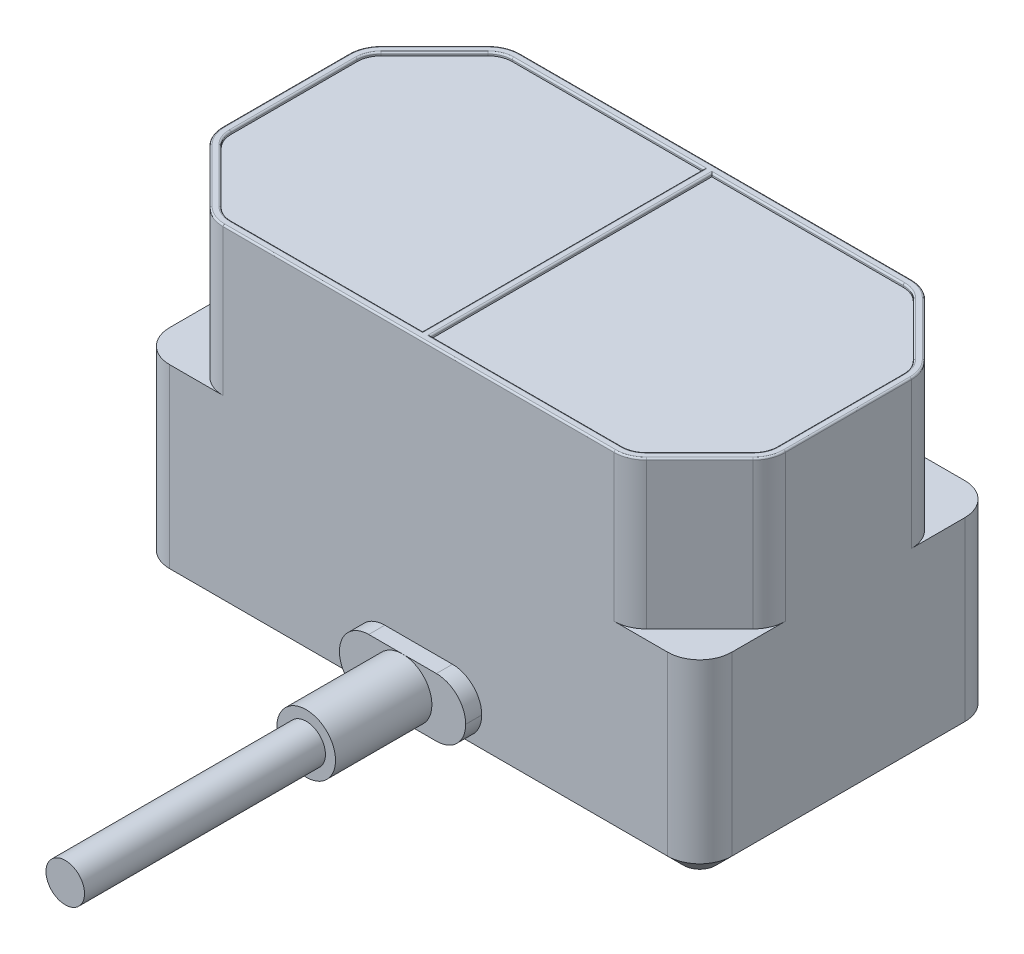
from build123d import *

# Parameters (mm, degrees)
SKETCH_1_W          = 35
SKETCH_1_H          = 18.5
EXTRUDE_1_DEPTH     = 12
EXTRUDE_2_DEPTH     = 9
FILLET_1_R          = 2
CHAMFER_1_SIZE      = 1
EXTRUDE_3_DEPTH     = 1
SKETCH_4_R          = 1.825
EXTRUDE_4_DEPTH     = 6
SKETCH_5_R          = 1.2
EXTRUDE_5_DEPTH     = 15
SKETCH_6_R          = 1
CUT_EXTRUDE_1_DEPTH = 4
FILLET_2_R          = 0.3
EXTRUDE_6_DEPTH     = 0.2
FILLET_3_R          = 0.1


with BuildPart() as part:
    # 草图1 → 凸台-拉伸1 (new body)
    with BuildSketch(Plane(origin=(0, 0, 0), x_dir=(1, 0, 0), z_dir=(0, 1, 0))):
        Rectangle(SKETCH_1_W, SKETCH_1_H)
    extrude(amount=EXTRUDE_1_DEPTH)

    # 草图2 → 凸台-拉伸2 (add)
    with BuildSketch(Plane(origin=(0, 12, 0), x_dir=(1, 0, 0), z_dir=(0, 1, 0))):
        Polygon((-13, 9.25), (-17.5, 4.75), (-17.5, -4.75), (-13, -9.25), (13, -9.25), (17.5, -4.75), (17.5, 4.75), (13, 9.25), align=None)
    extrude(amount=EXTRUDE_2_DEPTH)

    # 圆角1
    fillet_1_edges = [part.edges().sort_by_distance(p)[0] for p in [
        (13, 16.5, -9.25),
        (-13, 16.5, -9.25),
        (-17.5, 16.5, -4.75),
        (-17.5, 16.5, 4.75),
        (-13, 16.5, 9.25),
        (13, 16.5, 9.25),
        (17.5, 16.5, 4.75),
        (17.5, 16.5, -4.75),
        (17.5, 6, 9.25),
        (-17.5, 6, 9.25),
        (-17.5, 6, -9.25),
        (17.5, 6, -9.25),
    ]]
    fillet(fillet_1_edges, radius=FILLET_1_R)

    # 倒角1
    chamfer_1_edges = [part.edges().sort_by_distance(p)[0] for p in [
        (0, 0, -9.25),
        (-17.5, 0, 0),
        (17.5, 0, 0),
        (0, 0, 9.25),
        (-16.914213562, 0, 8.664213562),
        (-16.914213562, 0, -8.664213562),
        (16.914213562, 0, -8.664213562),
        (16.914213562, 0, 8.664213562),
    ]]
    chamfer(chamfer_1_edges, length=CHAMFER_1_SIZE)

    # 草图3 → 凸台-拉伸3 (add)
    with BuildSketch(Plane.XY.offset(9.25)):
        with BuildLine():
            Line((-2.106, 1), (2.106, 1))
            ThreePointArc((2.106, 1), (3.395762769, 1.534237231), (3.93, 2.824))
            Line((3.93, 2.824), (3.93, 2.826))
            ThreePointArc((3.93, 2.826), (3.395762769, 4.115762769), (2.106, 4.65))
            Line((2.106, 4.65), (-2.106, 4.65))
            ThreePointArc((-2.106, 4.65), (-3.395762769, 4.115762769), (-3.93, 2.826))
            Line((-3.93, 2.826), (-3.93, 2.824))
            ThreePointArc((-3.93, 2.824), (-3.395762769, 1.534237231), (-2.106, 1))
        make_face()
    extrude(amount=EXTRUDE_3_DEPTH)

    # 草图4 → 凸台-拉伸4 (add)
    with BuildSketch(Plane.XY.offset(10.25)):
        with Locations((0, 2.825)):
            Circle(SKETCH_4_R)
    extrude(amount=EXTRUDE_4_DEPTH)

    # 草图5 → 凸台-拉伸5 (add)
    with BuildSketch(Plane.XY.offset(16.25)):
        with Locations((0, 2.825)):
            Circle(SKETCH_5_R)
    extrude(amount=EXTRUDE_5_DEPTH)

    # 草图6 → 切除-拉伸1 (cut)
    with BuildSketch(Plane.XZ):
        with Locations((-14, 5.75)):
            Circle(SKETCH_6_R)
        with Locations((14, -5.75)):
            Circle(SKETCH_6_R)
    extrude(amount=-CUT_EXTRUDE_1_DEPTH, mode=Mode.SUBTRACT)

    # 圆角2
    fillet_2_edges = [part.edges().sort_by_distance(p)[0] for p in [
        (-15, 0, 5.75),
        (13, 0, -5.75),
    ]]
    fillet(fillet_2_edges, radius=FILLET_2_R)

    # 草图7 → 凸台-拉伸6 (add)
    with BuildSketch(Plane(origin=(0, 21, 0), x_dir=(1, 0, 0), z_dir=(0, 1, 0))):
        with BuildLine():
            Line((-16.914213562, 5.335786438), (-13.585786438, 8.664213562))
            ThreePointArc((-13.585786438, 8.664213562), (-12.93693974, 9.097759065), (-12.171572875, 9.25))
            Line((-12.171572875, 9.25), (12.171572875, 9.25))
            ThreePointArc((12.171572875, 9.25), (12.93693974, 9.097759065), (13.585786438, 8.664213562))
            Line((13.585786438, 8.664213562), (16.914213562, 5.335786438))
            ThreePointArc((16.914213562, 5.335786438), (17.347759065, 4.68693974), (17.5, 3.921572875))
            Line((17.5, 3.921572875), (17.5, -3.921572875))
            ThreePointArc((17.5, -3.921572875), (17.347759065, -4.68693974), (16.914213562, -5.335786438))
            Line((16.914213562, -5.335786438), (13.585786438, -8.664213562))
            ThreePointArc((13.585786438, -8.664213562), (12.93693974, -9.097759065), (12.171572875, -9.25))
            Line((12.171572875, -9.25), (-12.171572875, -9.25))
            ThreePointArc((-12.171572875, -9.25), (-12.93693974, -9.097759065), (-13.585786438, -8.664213562))
            Line((-13.585786438, -8.664213562), (-16.914213562, -5.335786438))
            ThreePointArc((-16.914213562, -5.335786438), (-17.347759065, -4.68693974), (-17.5, -3.921572875))
            Line((-17.5, -3.921572875), (-17.5, 3.921572875))
            ThreePointArc((-17.5, 3.921572875), (-17.347759065, 4.68693974), (-16.914213562, 5.335786438))
        make_face()
        with BuildLine():
            Line((-16.560660172, 4.982233047), (-13.232233047, 8.310660172))
            ThreePointArc((-13.232233047, 8.310660172), (-12.745598024, 8.635819299), (-12.171572875, 8.75))
            Line((-12.171572875, 8.75), (-0.25, 8.75))
            Line((-0.25, 8.75), (-0.25, -8.75))
            Line((-0.25, -8.75), (-12.171572875, -8.75))
            ThreePointArc((-12.171572875, -8.75), (-12.745598024, -8.635819299), (-13.232233047, -8.310660172))
            Line((-13.232233047, -8.310660172), (-16.560660172, -4.982233047))
            ThreePointArc((-16.560660172, -4.982233047), (-16.885819299, -4.495598024), (-17, -3.921572875))
            Line((-17, -3.921572875), (-17, 3.921572875))
            ThreePointArc((-17, 3.921572875), (-16.885819299, 4.495598024), (-16.560660172, 4.982233047))
        make_face(mode=Mode.SUBTRACT)
        with BuildLine():
            Line((13.232233047, 8.310660172), (16.560660172, 4.982233047))
            ThreePointArc((16.560660172, 4.982233047), (16.885819299, 4.495598024), (17, 3.921572875))
            Line((17, 3.921572875), (17, -3.921572875))
            ThreePointArc((17, -3.921572875), (16.885819299, -4.495598024), (16.560660172, -4.982233047))
            Line((16.560660172, -4.982233047), (13.232233047, -8.310660172))
            ThreePointArc((13.232233047, -8.310660172), (12.745598024, -8.635819299), (12.171572875, -8.75))
            Line((12.171572875, -8.75), (0.25, -8.75))
            Line((0.25, -8.75), (0.25, 8.75))
            Line((0.25, 8.75), (12.171572875, 8.75))
            ThreePointArc((12.171572875, 8.75), (12.745598024, 8.635819299), (13.232233047, 8.310660172))
        make_face(mode=Mode.SUBTRACT)
    extrude(amount=EXTRUDE_6_DEPTH)

    # 圆角3
    fillet_3_edges = [part.edges().sort_by_distance(p)[0] for p in [
        (12.93693974, 21.2, -9.097759065),
        (0, 21.2, -9.25),
        (-12.93693974, 21.2, -9.097759065),
        (-15.25, 21.2, -7),
        (-17.347759065, 21.2, -4.68693974),
        (-17.5, 21.2, 0),
        (-17.347759065, 21.2, 4.68693974),
        (-15.25, 21.2, 7),
        (-12.93693974, 21.2, 9.097759065),
        (0, 21.2, 9.25),
        (12.93693974, 21.2, 9.097759065),
        (15.25, 21.2, 7),
        (17.347759065, 21.2, 4.68693974),
        (17.5, 21.2, 0),
        (17.347759065, 21.2, -4.68693974),
        (15.25, 21.2, -7),
        (-16.885819299, 21.2, -4.495598024),
        (-17, 21.2, 0),
        (-16.885819299, 21.2, 4.495598024),
        (-14.896446609, 21.2, 6.646446609),
        (-12.745598024, 21.2, 8.635819299),
        (-6.210786438, 21.2, 8.75),
        (-0.25, 21.2, 0),
        (-6.210786438, 21.2, -8.75),
        (-12.745598024, 21.2, -8.635819299),
        (-14.896446609, 21.2, -6.646446609),
        (12.745598024, 21.2, -8.635819299),
        (6.210786438, 21.2, -8.75),
        (0.25, 21.2, 0),
        (6.210786438, 21.2, 8.75),
        (12.745598024, 21.2, 8.635819299),
        (14.896446609, 21.2, 6.646446609),
        (16.885819299, 21.2, 4.495598024),
        (17, 21.2, 0),
        (16.885819299, 21.2, -4.495598024),
        (14.896446609, 21.2, -6.646446609),
    ]]
    fillet(fillet_3_edges, radius=FILLET_3_R)


solid = part.part
